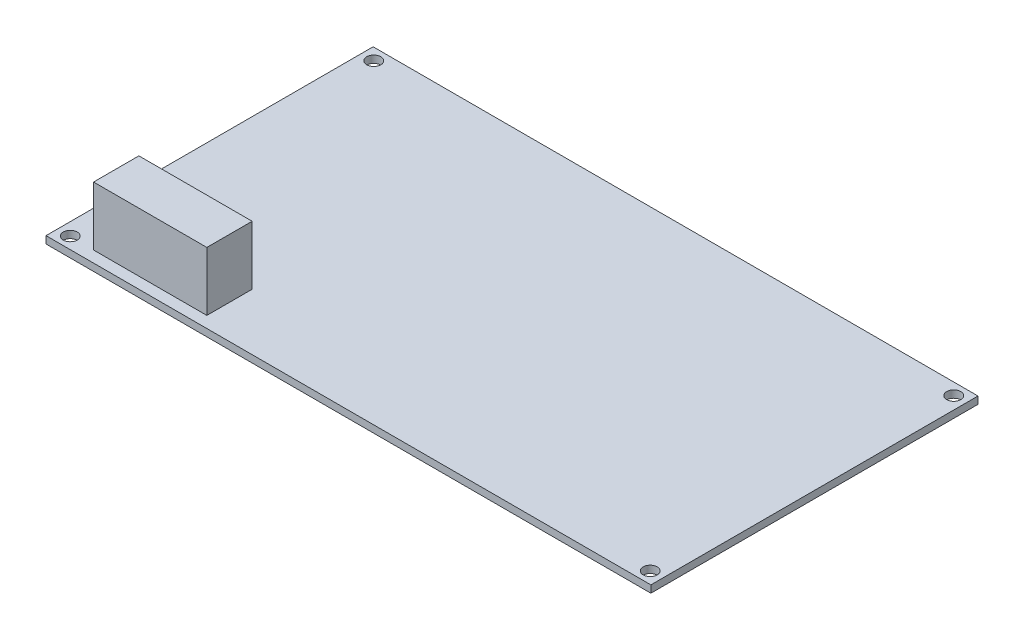
from build123d import *

# Parameters (mm, degrees)
SKETCH1_W           = 133.5
SKETCH1_H           = 72.2
SKETCH1_R           = 1.55
BOSS_EXTRUDE1_DEPTH = 1.6
SKETCH2_W           = 25
SKETCH2_H           = 10
BOSS_EXTRUDE2_DEPTH = 13


with BuildPart() as part:
    # Sketch1 → Boss-Extrude1 (new body)
    with BuildSketch(Plane(origin=(0, 0, 0), x_dir=(1, 0, 0), z_dir=(0, 1, 0))):
        with Locations((66.75, 36.1)):
            Rectangle(SKETCH1_W, SKETCH1_H)
        with Locations((2.75, 69.6)):
            Circle(SKETCH1_R, mode=Mode.SUBTRACT)
        with Locations((130.75, 69.6)):
            Circle(SKETCH1_R, mode=Mode.SUBTRACT)
        with Locations((130.75, 2.6)):
            Circle(SKETCH1_R, mode=Mode.SUBTRACT)
        with Locations((2.75, 2.6)):
            Circle(SKETCH1_R, mode=Mode.SUBTRACT)
    extrude(amount=BOSS_EXTRUDE1_DEPTH)

    # Sketch2 → Boss-Extrude2 (add)
    with BuildSketch(Plane(origin=(0, 1.6, 0), x_dir=(1, 0, 0), z_dir=(0, 1, 0))):
        with Locations((20.5, 7.5)):
            Rectangle(SKETCH2_W, SKETCH2_H)
    extrude(amount=BOSS_EXTRUDE2_DEPTH)


solid = part.part
